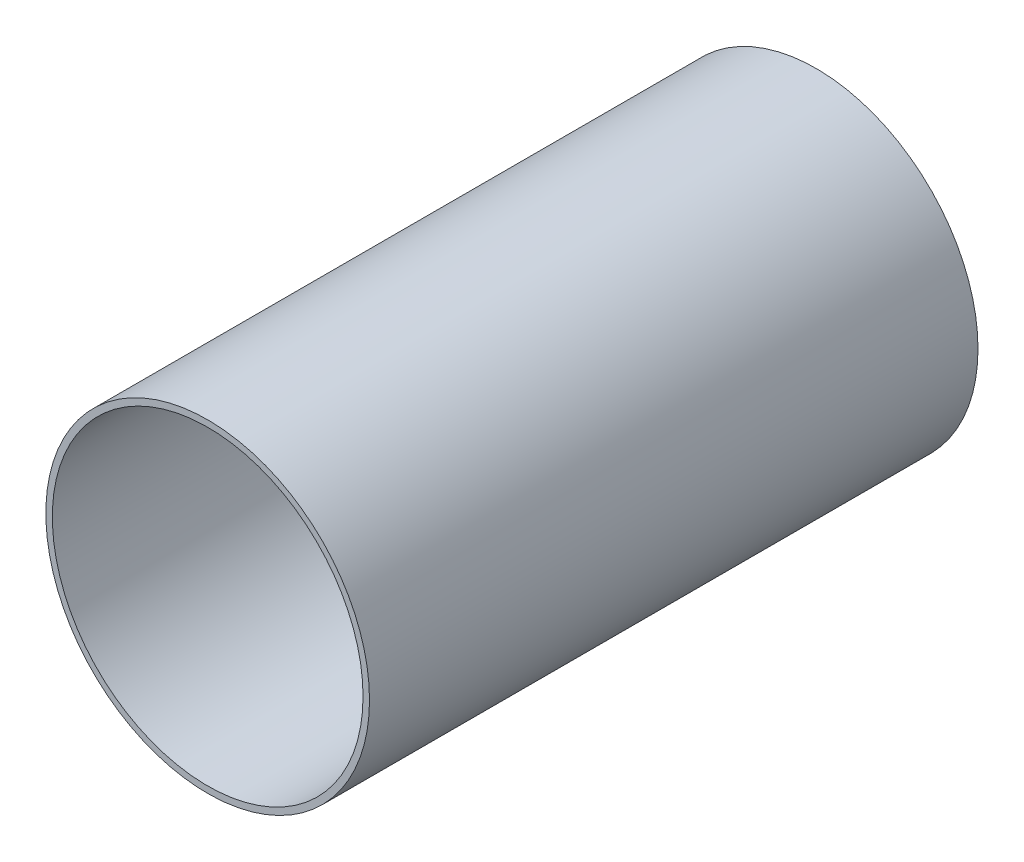
from build123d import *

# Parameters (mm, degrees)
SKETCH2_R           = 79.375
BOSS_EXTRUDE1_DEPTH = 298.45
SKETCH3_R           = 76.2
CUT_EXTRUDE1_DEPTH  = 298.45


with BuildPart() as part:
    # Sketch2 → Boss-Extrude1 (new body)
    with BuildSketch(Plane.XY):
        Circle(SKETCH2_R)
    extrude(amount=BOSS_EXTRUDE1_DEPTH)

    # Sketch3 → Cut-Extrude1 (cut)
    with BuildSketch(Plane.XY.offset(298.45)):
        Circle(SKETCH3_R)
    extrude(amount=-CUT_EXTRUDE1_DEPTH, mode=Mode.SUBTRACT)


solid = part.part
